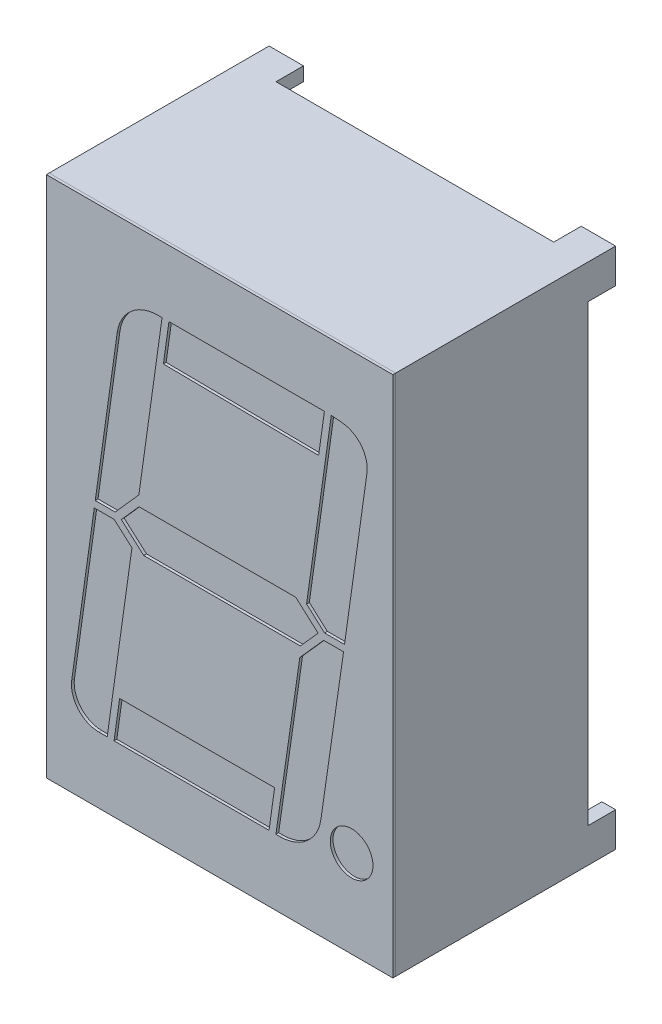
from build123d import *

# Parameters (mm, degrees)
SKETCH1_W           = 12.6
SKETCH1_H           = 19
BOSS_EXTRUDE1_DEPTH = 7
BOSS_EXTRUDE2_DEPTH = 1
SKETCH3_W           = 12.6
SKETCH3_H           = 19
BOSS_EXTRUDE3_DEPTH = 0.1
SKETCH4_R           = 0.776012873
CUT_EXTRUDE1_DEPTH  = 0.1


with BuildPart() as part:
    # Sketch1 → Boss-Extrude1 (new body)
    with BuildSketch(Plane.XY):
        Rectangle(SKETCH1_W, SKETCH1_H)
    extrude(amount=BOSS_EXTRUDE1_DEPTH)

    # Sketch2 → Boss-Extrude2 (add)
    with BuildSketch(Plane(origin=(0, 0, 0), x_dir=(-1, 0, 0), z_dir=(0, 0, -1))):
        Polygon((-6.3, 9.5), (-5.05, 9.5), (-5.05, 9), (-5.8, 9), (-5.8, 8.25), (-6.3, 8.25), align=None)
        Polygon((5.05, 9.5), (5.05, 9), (5.8, 9), (5.8, 8.25), (6.3, 8.25), (6.3, 9.5), align=None)
        Polygon((6.3, -8.25), (6.3, -9.5), (5.05, -9.5), (5.05, -9), (5.8, -9), (5.8, -8.25), align=None)
        Polygon((-5.05, -9.5), (-5.05, -9), (-5.8, -9), (-5.8, -8.25), (-6.3, -8.25), (-6.3, -9.5), align=None)
    extrude(amount=BOSS_EXTRUDE2_DEPTH)


with BuildPart() as body_2:
    # Sketch3 → Boss-Extrude3 (new body)
    with BuildSketch(Plane.XY.offset(7)):
        Rectangle(SKETCH3_W, SKETCH3_H)
    extrude(amount=BOSS_EXTRUDE3_DEPTH)

    # Sketch4 → Cut-Extrude1 (cut)
    with BuildSketch(Plane.XY.offset(7.1)):
        with Locations((4.8, -6.323987127)):
            Circle(SKETCH4_R)
        Polygon((-1.842687024, 7.1), (3.809991471, 7.1), (3.600153471, 5.606925049), (-2.04448802, 5.6641113), align=None)
        with BuildLine():
            Line((-3.72415902, 5.808759651), (-4.522959346, 0.125))
            Line((-4.522959346, 0.125), (-3.797959346, 0.125))
            Line((-3.797959346, 0.125), (-2.936837994, 1.093553748))
            Line((-2.936837994, 1.093553748), (-2.092687024, 7.1))
            Line((-2.092687024, 7.1), (-2.238756917, 7.1))
            ThreePointArc((-2.238756917, 7.1), (-3.222845461, 6.73206437), (-3.72415902, 5.808759651))
        make_face()
        with BuildLine():
            Line((-5.378266538, -5.960826899), (-4.558094555, -0.125))
            Line((-4.558094555, -0.125), (-3.833094555, -0.125))
            Line((-3.833094555, -0.125), (-3.188622604, -0.697986846))
            Line((-3.188622604, -0.697986846), (-4.088366877, -7.1))
            Line((-4.088366877, -7.1), (-4.38799847, -7.1))
            ThreePointArc((-4.38799847, -7.1), (-5.14270805, -6.756059029), (-5.378266538, -5.960826899))
        make_face()
        with BuildLine():
            Line((4.453734529, 7.065929798), (4.059991471, 7.1))
            Line((4.059991471, 7.1), (3.161598917, 0.707604826))
            Line((3.161598917, 0.707604826), (3.816888774, 0.125))
            Line((3.816888774, 0.125), (4.541888774, 0.125))
            Line((4.541888774, 0.125), (5.357795701, 5.930479441))
            ThreePointArc((5.357795701, 5.930479441), (5.149839249, 6.692539798), (4.453734529, 7.065929798))
        make_face()
        with BuildLine():
            Line((2.04682864, -7.1), (2.198374788, -7.1))
            ThreePointArc((2.198374788, -7.1), (3.180102847, -6.734111995), (3.682894212, -5.814946691))
            Line((3.682894212, -5.814946691), (4.506753566, -0.125))
            Line((4.506753566, -0.125), (3.781753566, -0.125))
            Line((3.781753566, -0.125), (2.915713605, -1.099085996))
            Line((2.915713605, -1.099085996), (2.04682864, -7.1))
        make_face()
        Polygon((-2.929991192, 0.725), (2.765778795, 0.725), (3.581228865, 0), (2.936646175, -0.725), (-2.759123811, -0.725), (-3.574573882, 0), align=None)
        Polygon((-3.838366877, -7.1), (1.79682864, -7.1), (1.9996392, -5.656927882), (-3.63656588, -5.6641113), align=None)
    extrude(amount=-CUT_EXTRUDE1_DEPTH, mode=Mode.SUBTRACT)


solid = Compound([part.part, body_2.part])
